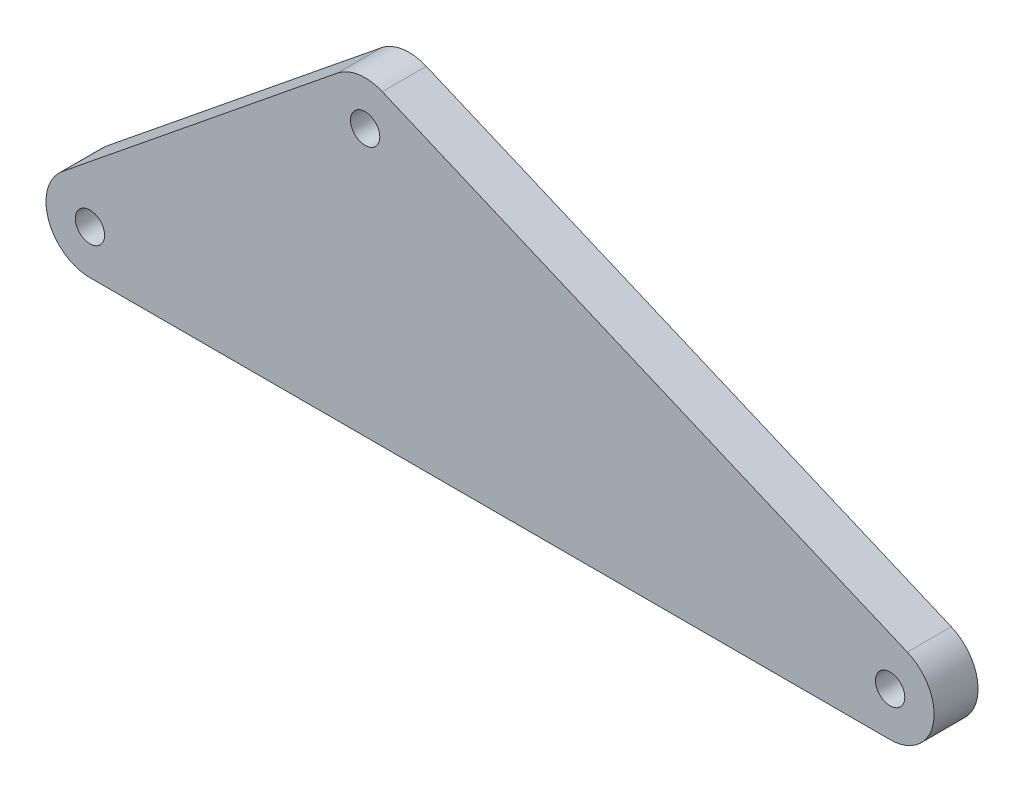
from build123d import *

# Parameters (mm, degrees)
SKETCH_1_R          = 10
EXTRUDE_1_DEPTH     = 15
SKETCH_2_R          = 20
CUT_EXTRUDE_1_DEPTH = 13


with BuildPart() as part:
    # Эскиз1 → Бобышка-Вытянуть1 (new body, symmetric)
    with BuildSketch(Plane.XY):
        with BuildLine():
            Line((-346.502827781, 179.672535461), (11.721933855, 27.615145604))
            ThreePointArc((11.721933855, 27.615145604), (29.397741139, -5.981038033), (0, -30))
            Line((0, -30), (-546, -30))
            ThreePointArc((-546, -30), (-574.279244733, -10.014205777), (-564.879611731, 23.314378844))
            Line((-564.879611731, 23.314378844), (-377.104373367, 175.371768701))
            ThreePointArc((-377.104373367, 175.371768701), (-362.399954664, 181.765431919), (-346.502827781, 179.672535461))
        make_face()
        with Locations((-546, 0)):
            Circle(SKETCH_1_R, mode=Mode.SUBTRACT)
        with Locations((-358.224761635, 152.057389857)):
            Circle(SKETCH_1_R, mode=Mode.SUBTRACT)
        Circle(SKETCH_1_R, mode=Mode.SUBTRACT)
    extrude(amount=EXTRUDE_1_DEPTH, both=True)

    # Эскиз2 → Вырез-Вытянуть1 (cut)
    with BuildSketch(Plane(origin=(0, 0, -15), x_dir=(-1, 0, 0), z_dir=(0, 0, -1))):
        with Locations((358.224761635, 152.057389857)):
            Circle(SKETCH_2_R)
    extrude(amount=-CUT_EXTRUDE_1_DEPTH, mode=Mode.SUBTRACT)


solid = part.part
